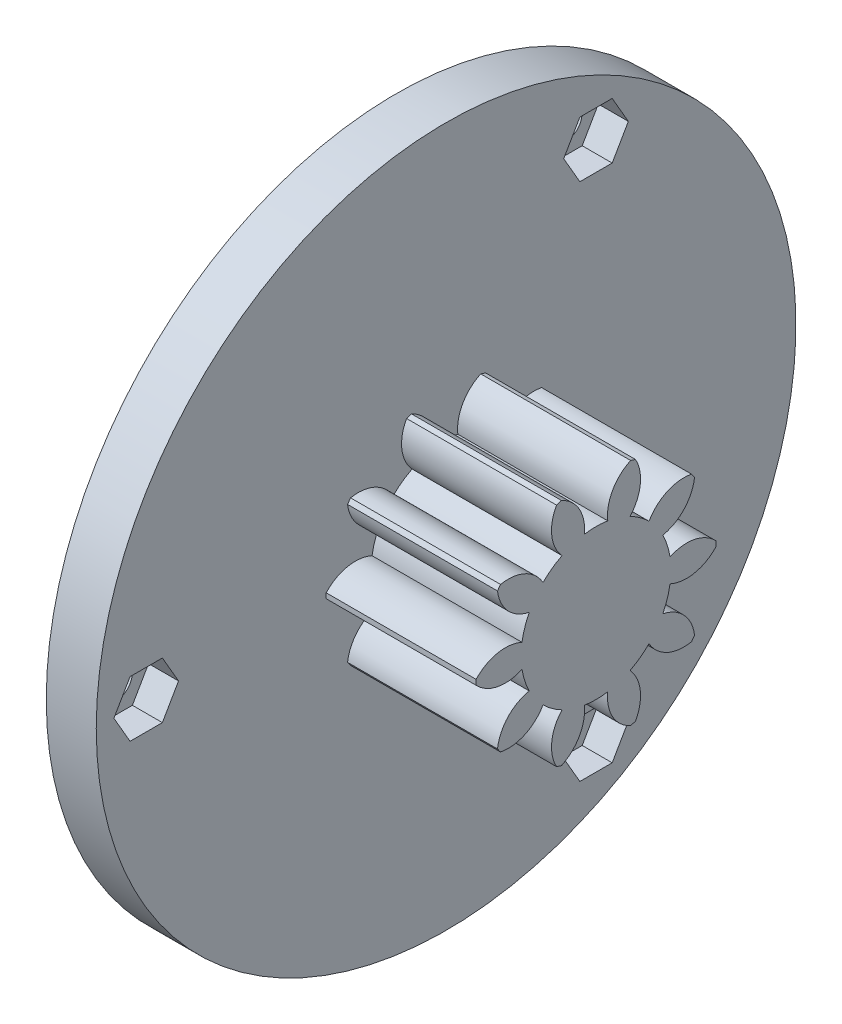
from build123d import *

# Parameters (mm, degrees)
BASPROSKE_W         = 15
BASPROSKE_H         = 12
TOOTHCUT_DEPTH      = 23.649503306
TEETHCUTS_COUNT     = 10
TEETHCUTS_ANGLE     = 324
BORSKE_R            = 0.45
BORE_DEPTH          = 50.0000508
SKETCH1_R           = 0.45
CUT_EXTRUDE1_DEPTH  = 15
SKETCH2_R           = 3.991106517
BOSS_EXTRUDE1_DEPTH = 15
SKETCH3_R           = 35
BOSS_EXTRUDE2_DEPTH = 5
SKETCH7_R           = 1.6
CUT_EXTRUDE2_DEPTH  = 10
CUT_EXTRUDE3_DEPTH  = 3
CUT_EXTRUDE5_DEPTH  = 3


with BuildPart() as part:
    # BasProSke → Base-Revolve (revolve)
    with BuildSketch(Plane(origin=(0, 0, 0), x_dir=(1, 0, 0), z_dir=(0, 1, 0)), mode=Mode.PRIVATE) as base_revolve_sk:
        with Locations((7.5, 6)):
            Rectangle(BASPROSKE_W, BASPROSKE_H)
    revolve(base_revolve_sk.sketch.rotate(Axis((-10, 0, 0), (1, 0, 0)), 180), axis=Axis((-10, 0, 0), (1, 0, 0)))

    # TooCutSke → ToothCut (cut, through all)
    with BuildSketch(Plane(origin=(0, 0, 0), x_dir=(0, 0, -1), z_dir=(1, 0, 0))):
        with BuildLine():
            ThreePointArc((1.173662691, 7.406586048), (0, 7.499), (-1.173662691, 7.406586048))
            ThreePointArc((-1.173662691, 7.406586048), (-1.668191438, 9.834565786), (-3.497907776, 11.50542856))
            ThreePointArc((-3.497907776, 11.50542856), (0, 12.0254), (3.497907776, 11.50542856))
            ThreePointArc((3.497907776, 11.50542856), (1.668191438, 9.834565786), (1.173662691, 7.406586048))
        make_face()
    toothcut = extrude(amount=TOOTHCUT_DEPTH, mode=Mode.SUBTRACT)

    # TeethCuts: ToothCut ×10 about axis
    teethcuts_axis = Axis((-10, 0, 0), (1, 0, 0))
    for i in range(1, TEETHCUTS_COUNT):
        add(toothcut.rotate(teethcuts_axis, i * TEETHCUTS_ANGLE / (TEETHCUTS_COUNT - 1)), mode=Mode.SUBTRACT)

    # BorSke → Bore (cut, symmetric)
    with BuildSketch(Plane(origin=(0, 0, 0), x_dir=(0, 0, -1), z_dir=(1, 0, 0))):
        with Locations(Location((0, 0, 0), (0, 0, 180))):
            Circle(BORSKE_R)
    extrude(amount=BORE_DEPTH, both=True, mode=Mode.SUBTRACT)

    # Sketch1 → Cut-Extrude1 (cut)
    with BuildSketch(Plane.ZY):
        with BuildLine():
            Line((1.212435565, 2.3), (-1.212435565, 2.3))
            ThreePointArc((-1.212435565, 2.3), (-1.343068786, -2.226244873), (2.6, 0))
            ThreePointArc((2.6, 0), (2.226244873, 1.343068786), (1.212435565, 2.3))
        make_face()
        Circle(SKETCH1_R, mode=Mode.SUBTRACT)
    extrude(amount=-CUT_EXTRUDE1_DEPTH, mode=Mode.SUBTRACT)

    # Sketch2 → Boss-Extrude1 (add)
    with BuildSketch(Plane.ZY):
        Circle(SKETCH2_R)
    extrude(amount=-BOSS_EXTRUDE1_DEPTH)

    # Sketch3 → Boss-Extrude2 (add)
    with BuildSketch(Plane.ZY):
        Circle(SKETCH3_R)
    extrude(amount=BOSS_EXTRUDE2_DEPTH)

    # Sketch7 → Cut-Extrude2 (cut)
    with BuildSketch(Plane.ZY.offset(5)):
        with Locations((30, 0)):
            Circle(SKETCH7_R)
        with Locations((-15, -25.980762114)):
            Circle(SKETCH7_R)
        with Locations((-15, 25.980762114)):
            Circle(SKETCH7_R)
    extrude(amount=-CUT_EXTRUDE2_DEPTH, mode=Mode.SUBTRACT)

    # Sketch8 → Cut-Extrude3 (cut)
    with BuildSketch(Plane(origin=(0, 0, 0), x_dir=(0, 0, -1), z_dir=(1, 0, 0))):
        Polygon((15.808290377, 27.380762114), (14.191709623, 27.380762114), (13.383419246, 25.980762114), (14.191709623, 24.580762114), (15.808290377, 24.580762114), (16.616580754, 25.980762114), align=None)
        Polygon((-31.616580754, 0), (-30.808290377, -1.4), (-29.191709623, -1.4), (-28.383419246, 0), (-29.191709623, 1.4), (-30.808290377, 1.4), align=None)
        Polygon((15.808290377, -27.380762114), (16.616580754, -25.980762114), (15.808290377, -24.580762114), (14.191709623, -24.580762114), (13.383419246, -25.980762114), (14.191709623, -27.380762114), align=None)
    extrude(amount=-CUT_EXTRUDE3_DEPTH, mode=Mode.SUBTRACT)

    # Sketch9 → Cut-Extrude5 (cut)
    with BuildSketch(Plane(origin=(0, 0, 0), x_dir=(0, 0, -1), z_dir=(1, 0, 0))):
        Polygon((16.616580754, 28.780762114), (13.383419246, 28.780762114), (11.766838493, 25.980762114), (13.383419246, 23.180762114), (16.616580754, 23.180762114), (18.233161507, 25.980762114), align=None)
        Polygon((-33.233161507, 0), (-31.616580754, -2.8), (-28.383419246, -2.8), (-26.766838493, 0), (-28.383419246, 2.8), (-31.616580754, 2.8), align=None)
        Polygon((16.616580754, -28.780762114), (18.233161507, -25.980762114), (16.616580754, -23.180762114), (13.383419246, -23.180762114), (11.766838493, -25.980762114), (13.383419246, -28.780762114), align=None)
    extrude(amount=-CUT_EXTRUDE5_DEPTH, mode=Mode.SUBTRACT)


solid = part.part
